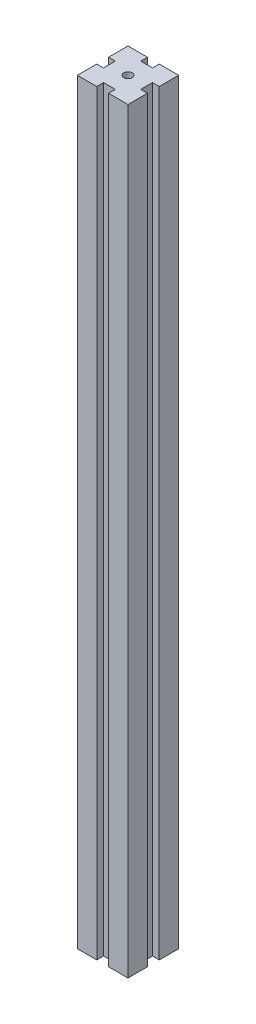
from build123d import *

# Parameters (mm, degrees)
BOSS_EXTRUDE1_DEPTH = 224
SKETCH2_R           = 1.25
CUT_EXTRUDE1_DEPTH  = 225


with BuildPart() as part:
    # Sketch1 → Boss-Extrude1 (new body)
    with BuildSketch(Plane(origin=(0, 0, 0), x_dir=(1, 0, 0), z_dir=(0, 1, 0))):
        Polygon((0, 5.75), (0, 0), (5.75, 0), (5.75, 2), (9.25, 2), (9.25, 0), (15, 0), (15, 5.75), (13, 5.75), (13, 9.25), (15, 9.25), (15, 15), (9.25, 15), (9.25, 13), (5.75, 13), (5.75, 15), (0, 15), (0, 9.25), (2, 9.25), (2, 5.75), align=None)
    extrude(amount=BOSS_EXTRUDE1_DEPTH)

    # Sketch2 → Cut-Extrude1 (cut, through all)
    with BuildSketch(Plane(origin=(0, 224, 0), x_dir=(1, 0, 0), z_dir=(0, 1, 0))):
        with Locations((7.5, 7.5)):
            Circle(SKETCH2_R)
    extrude(amount=-CUT_EXTRUDE1_DEPTH, mode=Mode.SUBTRACT)


solid = part.part
